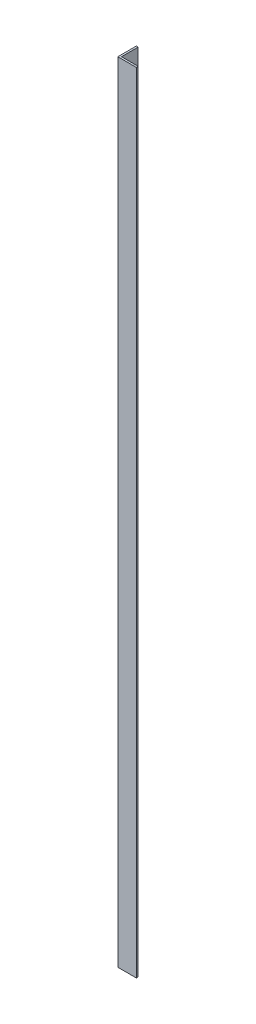
from build123d import *

# Parameters (mm, degrees)
EXTRUDE_1_DEPTH = 2125


with BuildPart() as part:
    # Эскиз1 → Вытянуть-Тонкостенный1 (new body)
    with BuildSketch(Plane(origin=(0, 0, 0), x_dir=(1, 0, 0), z_dir=(0, 1, 0))):
        Polygon((0, 50), (0, 0), (50, 0), (50, 5), (5, 5), (5, 50), align=None)
    extrude(amount=EXTRUDE_1_DEPTH)


solid = part.part
